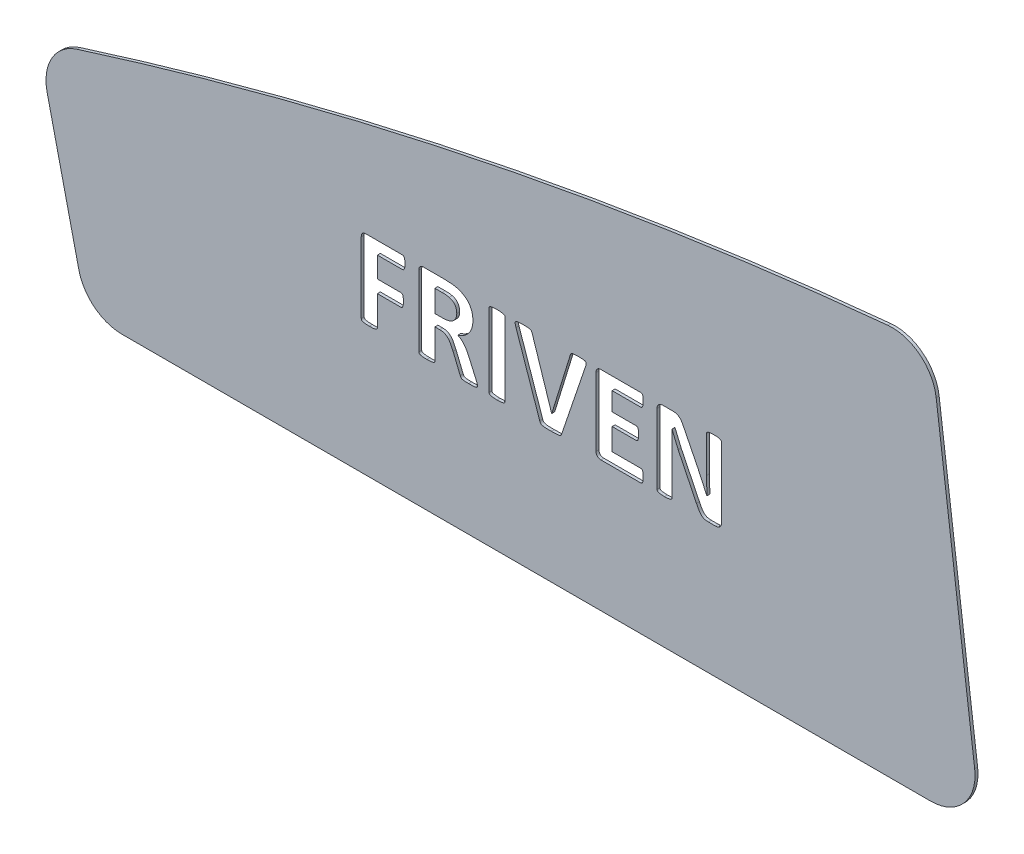
from build123d import *

# Parameters (mm, degrees)
RESSALTO_EXTRUS_O1_DEPTH = 1
CORTE_EXTRUS_O1_DEPTH    = 2.0000001


with BuildPart() as part:
    # Esboço1 → Ressalto-extrusão1 (new body)
    with BuildSketch(Plane.XY):
        with BuildLine():
            Line((94.444598391, 61.667599804), (367.776904696, 61.667599804))
            ThreePointArc((367.776904696, 61.667599804), (379.03385921, 66.75392364), (382.656611581, 78.563469793))
            Line((382.656611581, 78.563469793), (369.641986092, 180.708560753))
            ThreePointArc((369.641986092, 180.708560753), (364.126605538, 190.530599808), (353.330083137, 193.744161368))
            add(Edge.make_bspline(
                [(79.194488068, 137.503422788), (169.384224686, 166.11838017), (260.762756376, 184.86529303), (353.330083137, 193.744161368)],
                knots=[0.031642667, 0.031642667, 0.031642667, 0.031642667, 0.681355193, 0.681355193, 0.681355193, 0.681355193], degree=3))
            ThreePointArc((79.194488068, 137.503422788), (70.703408387, 130.641376571), (69.113130899, 119.840583547))
            Line((69.113130899, 119.840583547), (79.826960066, 73.302388103))
            ThreePointArc((79.826960066, 73.302388103), (85.103243444, 64.931370096), (94.444598391, 61.667599804))
        make_face()
    extrude(amount=RESSALTO_EXTRUS_O1_DEPTH)

    # Esboço2 → Corte-extrusão1 (cut, through all)
    with BuildSketch(Plane.XY.offset(1)):
        with BuildLine():
            add(Edge.make_bspline(
                [(190.074469714, 130.135297285), (190.073615824, 129.952721273), (190.072047442, 129.617375054), (190.025612284, 129.161274081), (189.974615654, 128.78716653), (189.877432942, 128.498499337), (189.758996776, 128.278558112), (189.621720542, 128.122269327), (189.458159733, 128.025974502), (189.34199356, 128.013605785), (189.284124279, 128.007444191)],
                knots=[0, 0, 0, 0, 0.000547297, 0.001005248, 0.001375054, 0.001676898, 0.001913689, 0.002120216, 0.002294415, 0.002467336, 0.002467336, 0.002467336, 0.002467336], degree=3))
            Line((189.284124279, 128.007444191), (180.73623442, 128.007444191))
            Line((180.73623442, 128.007444191), (180.73623442, 121.00376772))
            Line((180.73623442, 121.00376772), (188.755200795, 121.00376772))
            add(Edge.make_bspline(
                [(188.755200795, 121.00376772), (188.813073192, 120.999832249), (188.928600555, 120.991976091), (189.088132877, 120.901725823), (189.236126152, 120.762871005), (189.3470074, 120.541728002), (189.446240967, 120.254949404), (189.496495394, 119.880152168), (189.543567249, 119.420261457), (189.544844107, 119.08081137), (189.545546231, 118.894153367)],
                knots=[0, 0, 0, 0, 0.000171956, 0.000343267, 0.000536766, 0.000773557, 0.001075401, 0.001445208, 0.001903158, 0.002462611, 0.002462611, 0.002462611, 0.002462611], degree=3))
            add(Edge.make_bspline(
                [(189.545546231, 118.894153367), (189.544856054, 118.707506484), (189.543600923, 118.368076621), (189.496192966, 117.906073981), (189.445448264, 117.525808413), (189.345610124, 117.226831185), (189.235032479, 116.99263671), (189.094249199, 116.831280767), (188.927549701, 116.743578819), (188.81282935, 116.730375672), (188.755200795, 116.72374321)],
                knots=[0, 0, 0, 0, 0.000559454, 0.001017404, 0.001393208, 0.001706587, 0.001959457, 0.002165983, 0.002337294, 0.002510215, 0.002510215, 0.002510215, 0.002510215], degree=3))
            Line((188.755200795, 116.72374321), (180.73623442, 116.72374321))
            Line((180.73623442, 116.72374321), (180.73623442, 106.741072408))
            add(Edge.make_bspline(
                [(180.73623442, 106.741072408), (180.731322982, 106.668872202), (180.721688386, 106.527239571), (180.613941345, 106.331580126), (180.424704144, 106.168582967), (180.142156824, 106.050961066), (179.771202878, 105.94719517), (179.293371773, 105.879013596), (178.696208815, 105.840019747), (178.255850081, 105.833008561), (178.012582459, 105.829135367)],
                knots=[0, 0, 0, 0, 0.000214946, 0.000421651, 0.000649858, 0.000951763, 0.001330897, 0.001804676, 0.002395928, 0.003125706, 0.003125706, 0.003125706, 0.003125706], degree=3))
            add(Edge.make_bspline(
                [(178.012582459, 105.829135367), (177.773437513, 105.833330882), (177.335238963, 105.841018557), (176.739358176, 105.877291174), (176.261949751, 105.9507416), (175.888228402, 106.040552911), (175.614218447, 106.167799259), (175.415134127, 106.316961632), (175.312426266, 106.514334314), (175.296802348, 106.652979573), (175.288930498, 106.722833667)],
                knots=[0, 0, 0, 0, 0.000717622, 0.001314939, 0.001788717, 0.002166239, 0.002462646, 0.0026915, 0.002898206, 0.003108106, 0.003108106, 0.003108106, 0.003108106], degree=3))
            Line((175.288930498, 106.722833667), (175.288930498, 130.597345386))
            add(Edge.make_bspline(
                [(175.288930498, 130.597345386), (175.294676682, 130.73559093), (175.305533166, 130.996783546), (175.386853165, 131.357417735), (175.529677887, 131.659860324), (175.735929227, 131.893800085), (175.983966366, 132.070679309), (176.25792759, 132.199189033), (176.559615, 132.274916467), (176.767854396, 132.283185957), (176.875700949, 132.287468701)],
                knots=[0, 0, 0, 0, 0.000414528, 0.000783183, 0.001101302, 0.001407281, 0.001707652, 0.002009557, 0.002310358, 0.002633492, 0.002633492, 0.002633492, 0.002633492], degree=3))
            Line((176.875700949, 132.287468701), (189.278044699, 132.287468701))
            add(Edge.make_bspline(
                [(189.278044699, 132.287468701), (189.338076259, 132.284115623), (189.45686498, 132.277480649), (189.619256436, 132.179904821), (189.756085183, 132.025159638), (189.870977578, 131.801843793), (189.967851713, 131.505262599), (190.027462089, 131.124108941), (190.071310928, 130.659174697), (190.073356877, 130.319858813), (190.074469714, 130.135297285)],
                knots=[0, 0, 0, 0, 0.000177977, 0.000352176, 0.000550113, 0.00079223, 0.001099835, 0.001482655, 0.001946659, 0.002500034, 0.002500034, 0.002500034, 0.002500034], degree=3))
        make_face()
        with BuildLine():
            add(Edge.make_bspline(
                [(214.587337361, 106.637719543), (214.585061708, 106.570340863), (214.580720061, 106.441791176), (214.511741666, 106.25678623), (214.353672168, 106.095934848), (214.078508234, 105.991700878), (213.685426101, 105.912009402), (213.271036266, 105.868007519), (212.859006397, 105.84301419), (212.479628727, 105.844273608), (212.046205483, 105.824576415), (211.740093447, 105.827556702), (211.577945128, 105.829135367)],
                knots=[0, 0, 0, 0, 0.000201453, 0.000384347, 0.000577846, 0.0008581, 0.001250457, 0.001782863, 0.002105597, 0.002488659, 0.00292048, 0.003406846, 0.003406846, 0.003406846, 0.003406846], degree=3))
            add(Edge.make_bspline(
                [(211.577945128, 105.829135367), (211.318615134, 105.832972079), (210.856546314, 105.839808252), (210.240370404, 105.851656107), (209.764366015, 105.914877183), (209.400533767, 105.997080976), (209.130172746, 106.122585477), (208.947673713, 106.294524299), (208.842489111, 106.50376543), (208.782391836, 106.647572918), (208.750940302, 106.722833667)],
                knots=[0, 0, 0, 0, 0.000778281, 0.001386725, 0.001846729, 0.002216835, 0.002502317, 0.0027302, 0.002953412, 0.003198488, 0.003198488, 0.003198488, 0.003198488], degree=3))
            Line((208.750940302, 106.722833667), (206.343426515, 112.607867368))
            add(Edge.make_bspline(
                [(206.343426515, 112.607867368), (206.202043401, 112.925188899), (205.934863175, 113.524850596), (205.516212453, 114.360797994), (205.087748544, 115.084883724), (204.593222382, 115.676197168), (204.037605014, 116.149430953), (203.394006811, 116.482588837), (202.659952119, 116.69239169), (202.137900875, 116.712923034), (201.862775857, 116.72374321)],
                knots=[0, 0, 0, 0, 0.001042023, 0.001969174, 0.002804381, 0.003559449, 0.004271695, 0.004978732, 0.005717795, 0.006541258, 0.006541258, 0.006541258, 0.006541258], degree=3))
            Line((201.862775857, 116.72374321), (200.190891283, 116.72374321))
            Line((200.190891283, 116.72374321), (200.190891283, 106.686356185))
            add(Edge.make_bspline(
                [(200.190891283, 106.686356185), (200.185797325, 106.620112443), (200.175416399, 106.485114959), (200.060535528, 106.300416451), (199.869363014, 106.147465128), (199.588168031, 106.03777516), (199.217674696, 105.951458951), (198.742345554, 105.877378866), (198.142624739, 105.840453206), (197.700326055, 105.83317242), (197.455080161, 105.829135367)],
                knots=[0, 0, 0, 0, 0.000196907, 0.000401275, 0.000630129, 0.000921505, 0.001297507, 0.001771285, 0.002362538, 0.003098393, 0.003098393, 0.003098393, 0.003098393], degree=3))
            add(Edge.make_bspline(
                [(197.455080161, 105.829135367), (197.215931371, 105.833333815), (196.777725779, 105.841026865), (196.179886764, 105.877388326), (195.70090928, 105.951405309), (195.328790855, 106.035843776), (195.05313787, 106.149938501), (194.859268071, 106.296822059), (194.761709654, 106.488695685), (194.749611918, 106.62064612), (194.743587361, 106.686356185)],
                knots=[0, 0, 0, 0, 0.000717622, 0.001314939, 0.001794725, 0.002170727, 0.002456532, 0.002685386, 0.002883882, 0.003080789, 0.003080789, 0.003080789, 0.003080789], degree=3))
            Line((194.743587361, 106.686356185), (194.743587361, 130.597345386))
            add(Edge.make_bspline(
                [(194.743587361, 130.597345386), (194.74954361, 130.735485009), (194.76079698, 130.996477502), (194.839706103, 131.359318851), (194.991538603, 131.65829419), (195.196214772, 131.894051464), (195.444844671, 132.070518268), (195.720334745, 132.200427997), (196.024617996, 132.274195393), (196.234723533, 132.282967977), (196.342516972, 132.287468701)],
                knots=[0, 0, 0, 0, 0.000414528, 0.000783183, 0.001104021, 0.00141, 0.00171037, 0.002012275, 0.002318978, 0.002642112, 0.002642112, 0.002642112, 0.002642112], degree=3))
            Line((196.342516972, 132.287468701), (203.200283516, 132.287468701))
            add(Edge.make_bspline(
                [(203.200283516, 132.287468701), (203.366476938, 132.288738303), (203.684730576, 132.29116954), (204.138550757, 132.274709286), (204.546089361, 132.265961955), (205.016230874, 132.239778773), (205.545757915, 132.208036749), (205.954433633, 132.167110774), (206.148879947, 132.147638354)],
                knots=[0, 0, 0, 0, 0.000498526, 0.000954656, 0.00136217, 0.001721328, 0.002367167, 0.002953366, 0.002953366, 0.002953366, 0.002953366], degree=3))
            add(Edge.make_bspline(
                [(206.148879947, 132.147638354), (206.408743461, 132.10573975), (206.919056548, 132.023460381), (207.662503652, 131.856566784), (208.361397787, 131.634481267), (209.02165765, 131.381470524), (209.638022166, 131.082648678), (210.208151312, 130.743936139), (210.732849017, 130.365265653), (211.199621245, 129.937191845), (211.622871307, 129.472758691), (211.997235251, 128.96854387), (212.306302385, 128.414148945), (212.568843542, 127.824610444), (212.776488391, 127.19129397), (212.929909442, 126.516147137), (213.012719539, 125.792490633), (213.024763861, 125.296148147), (213.030964812, 125.040609019)],
                knots=[0, 0, 0, 0, 0.000789597, 0.001550589, 0.002283198, 0.002987695, 0.00367018, 0.004335387, 0.004975016, 0.005607672, 0.00623174, 0.006857967, 0.007486873, 0.008131939, 0.00879137, 0.009483108, 0.01020553, 0.01097216, 0.01097216, 0.01097216, 0.01097216], degree=3))
            add(Edge.make_bspline(
                [(213.030964812, 125.040609019), (213.028988511, 124.823517426), (213.025136437, 124.400376827), (212.950386583, 123.779776597), (212.855277525, 123.186089256), (212.698361077, 122.624678052), (212.510942691, 122.093774887), (212.285102993, 121.590318655), (212.016898087, 121.117351766), (211.713036865, 120.669187241), (211.362330694, 120.256055439), (210.980120404, 119.865862566), (210.558139099, 119.503994775), (209.933057632, 119.06561458), (209.06633485, 118.572327062), (208.30806726, 118.303090642), (207.918037805, 118.164603734)],
                knots=[0, 0, 0, 0, 0.000650771, 0.001268439, 0.001873136, 0.00245274, 0.003014238, 0.003561164, 0.004105617, 0.004643549, 0.005182989, 0.005728968, 0.006280906, 0.00684771, 0.008018089, 0.009257727, 0.009257727, 0.009257727, 0.009257727], degree=3))
            add(Edge.make_bspline(
                [(207.918037805, 118.164603734), (208.117106709, 118.063540911), (208.515343097, 117.861365217), (209.071026448, 117.478105784), (209.599063893, 117.029606374), (210.083414075, 116.486573407), (210.54527994, 115.866072525), (210.977983353, 115.157840455), (211.391919766, 114.361652035), (211.645851475, 113.792801291), (211.778571276, 113.495486087)],
                knots=[0, 0, 0, 0, 0.000669113, 0.001338557, 0.002019742, 0.002742777, 0.003516104, 0.00433777, 0.005229709, 0.006206328, 0.006206328, 0.006206328, 0.006206328], degree=3))
            Line((211.778571276, 113.495486087), (214.064493458, 108.321763278))
            add(Edge.make_bspline(
                [(214.064493458, 108.321763278), (214.11380818, 108.202463812), (214.204535552, 107.982981141), (214.320286704, 107.67624282), (214.412675098, 107.42114832), (214.496026464, 107.163099595), (214.568268584, 106.909181197), (214.581616772, 106.719157409), (214.587337361, 106.637719543)],
                knots=[0, 0, 0, 0, 0.000387236, 0.000712423, 0.000983561, 0.001200816, 0.001526684, 0.00177108, 0.00177108, 0.00177108, 0.00177108], degree=3))
        make_face()
        with BuildLine():
            add(Edge.make_bspline(
                [(207.58366089, 124.359696029), (207.577679133, 124.566991555), (207.566082997, 124.968851208), (207.447731596, 125.544582913), (207.258133173, 126.069533393), (206.995560447, 126.546682349), (206.644205783, 126.967938166), (206.193379941, 127.321199225), (205.64508711, 127.600884923), (205.2373157, 127.724145937), (205.024157597, 127.788579301)],
                knots=[0, 0, 0, 0, 0.000621189, 0.001204227, 0.001754286, 0.002290462, 0.002829903, 0.003388199, 0.003997281, 0.004664402, 0.004664402, 0.004664402, 0.004664402], degree=3))
            add(Edge.make_bspline(
                [(205.024157597, 127.788579301), (204.876608143, 127.821026812), (204.565255862, 127.889496102), (204.153793457, 127.942911094), (203.777957699, 127.971908261), (203.439941813, 128.001536702), (203.050250363, 127.999972334), (202.774687457, 128.004857799), (202.628802971, 128.007444191)],
                knots=[0, 0, 0, 0, 0.000453082, 0.000956073, 0.001242846, 0.00158417, 0.001973311, 0.002411083, 0.002411083, 0.002411083, 0.002411083], degree=3))
            Line((202.628802971, 128.007444191), (200.190891283, 128.007444191))
            Line((200.190891283, 128.007444191), (200.190891283, 120.614674583))
            Line((200.190891283, 120.614674583), (202.957100305, 120.614674583))
            add(Edge.make_bspline(
                [(202.957100305, 120.614674583), (203.143631916, 120.618531796), (203.505189803, 120.626008309), (204.031822371, 120.673518616), (204.521388831, 120.75842622), (204.97809763, 120.872744116), (205.394151628, 121.024798379), (205.777473811, 121.202343945), (206.122695898, 121.407019593), (206.529987889, 121.715290658), (206.952957024, 122.174225247), (207.321624628, 122.827065783), (207.545010252, 123.567249678), (207.570537719, 124.090634262), (207.58366089, 124.359696029)],
                knots=[0, 0, 0, 0, 0.000559619, 0.00108472, 0.001584467, 0.002048949, 0.002495125, 0.002911255, 0.003314758, 0.003696563, 0.004440883, 0.005167819, 0.005929491, 0.006735305, 0.006735305, 0.006735305, 0.006735305], degree=3))
        make_face(mode=Mode.SUBTRACT)
        with BuildLine():
            add(Edge.make_bspline(
                [(223.925572655, 106.680276605), (223.920162719, 106.616159709), (223.908961259, 106.483403447), (223.795366727, 106.300073716), (223.602694414, 106.148615741), (223.327330889, 106.029106049), (222.955106947, 105.954031012), (222.483444903, 105.876274958), (221.885291656, 105.840971493), (221.445097434, 105.833347239), (221.201920694, 105.829135367)],
                knots=[0, 0, 0, 0, 0.000190903, 0.000395271, 0.000624125, 0.000917964, 0.001286619, 0.001760398, 0.002351651, 0.003081428, 0.003081428, 0.003081428, 0.003081428], degree=3))
            add(Edge.make_bspline(
                [(221.201920694, 105.829135367), (220.962816591, 105.833535308), (220.524692882, 105.841597564), (219.928354272, 105.875578726), (219.453169701, 105.955146482), (219.07791921, 106.027851522), (218.8020868, 106.149126215), (218.606757026, 106.298195955), (218.503710169, 106.485809782), (218.486613054, 106.616495081), (218.478268734, 106.680276605)],
                knots=[0, 0, 0, 0, 0.000717622, 0.001314939, 0.001788717, 0.002163291, 0.00245713, 0.002685984, 0.002887346, 0.00307931, 0.00307931, 0.00307931, 0.00307931], degree=3))
            Line((218.478268734, 106.680276605), (218.478268734, 131.436327463))
            add(Edge.make_bspline(
                [(218.478268734, 131.436327463), (218.486022383, 131.50235081), (218.501456185, 131.633771677), (218.609449462, 131.820864812), (218.806247677, 131.966671854), (219.088129311, 132.080517953), (219.462122729, 132.164219134), (219.937106893, 132.237286722), (220.528170183, 132.285919531), (220.962684964, 132.286918621), (221.201920694, 132.287468701)],
                knots=[0, 0, 0, 0, 0.000197937, 0.000393997, 0.000627567, 0.000918943, 0.001300846, 0.001774624, 0.002360287, 0.00307778, 0.00307778, 0.00307778, 0.00307778], degree=3))
            add(Edge.make_bspline(
                [(221.201920694, 132.287468701), (221.445236486, 132.287007508), (221.885872915, 132.286172304), (222.482727487, 132.23702709), (222.956755659, 132.166596566), (223.32448283, 132.077642264), (223.604396626, 131.96940247), (223.792922287, 131.816754788), (223.911313725, 131.636410915), (223.920837632, 131.502770024), (223.925572655, 131.436327463)],
                knots=[0, 0, 0, 0, 0.000729651, 0.001321372, 0.001795151, 0.002165257, 0.002456633, 0.002685487, 0.002884634, 0.003081541, 0.003081541, 0.003081541, 0.003081541], degree=3))
            Line((223.925572655, 131.436327463), (223.925572655, 106.680276605))
        make_face()
        with BuildLine():
            add(Edge.make_bspline(
                [(243.076250504, 106.880902754), (243.041917466, 106.775846878), (242.97782773, 106.579738301), (242.820574512, 106.319374555), (242.586859705, 106.110860081), (242.245451332, 105.978370283), (241.793597084, 105.892306838), (241.338039766, 105.86019851), (240.899790902, 105.847128346), (240.508729594, 105.833252448), (240.066872939, 105.827905816), (239.756799883, 105.828709766), (239.59265101, 105.829135367)],
                knots=[0, 0, 0, 0, 0.000330877, 0.00061765, 0.000901899, 0.001253149, 0.001700277, 0.002279882, 0.002620555, 0.003015915, 0.003453687, 0.003946133, 0.003946133, 0.003946133, 0.003946133], degree=3))
            add(Edge.make_bspline(
                [(239.59265101, 105.829135367), (239.337311468, 105.828768784), (238.865126496, 105.828090883), (238.210414596, 105.832365258), (237.658833217, 105.848270948), (237.19963441, 105.881501317), (236.824733564, 105.938048409), (236.51827191, 105.998691386), (236.274582937, 106.094113295), (236.073660014, 106.201346139), (235.91676278, 106.339361383), (235.793689931, 106.50712413), (235.707839622, 106.713806389), (235.656270845, 106.86242641), (235.628764674, 106.941698557)],
                knots=[0, 0, 0, 0, 0.000766027, 0.001416571, 0.001964037, 0.002421462, 0.002796331, 0.003101645, 0.003355681, 0.003578894, 0.003781354, 0.003977131, 0.004197511, 0.004449428, 0.004449428, 0.004449428, 0.004449428], degree=3))
            Line((235.628764674, 106.941698557), (227.621957459, 130.177854347))
            add(Edge.make_bspline(
                [(227.621957459, 130.177854347), (227.585392662, 130.293316768), (227.516309199, 130.511464951), (227.420932686, 130.817515734), (227.363304996, 131.089160009), (227.313958769, 131.320497909), (227.302366428, 131.525601268), (227.342183508, 131.700909156), (227.407740054, 131.855643015), (227.524383594, 131.980947956), (227.683378325, 132.080500195), (227.887926067, 132.148673319), (228.132440682, 132.202928517), (228.423736955, 132.237167792), (228.76669442, 132.259048622), (229.170002488, 132.279366129), (229.634322239, 132.280645927), (229.96463148, 132.285112253), (230.138903691, 132.287468701)],
                knots=[0, 0, 0, 0, 0.000363404, 0.000686596, 0.000960919, 0.00119583, 0.001396548, 0.001570641, 0.001731146, 0.001894731, 0.002075183, 0.002288662, 0.002537925, 0.002825984, 0.003167308, 0.003568975, 0.004037142, 0.004560021, 0.004560021, 0.004560021, 0.004560021], degree=3))
            add(Edge.make_bspline(
                [(230.138903691, 132.287468701), (230.288889882, 132.288808028), (230.570683049, 132.291324349), (230.967730589, 132.274871683), (231.312526697, 132.266038809), (231.685808784, 132.241988344), (232.062735264, 132.205706922), (232.42651556, 132.123666169), (232.698897489, 132.003593547), (232.862122936, 131.799466504), (232.976915786, 131.564379877), (233.036838212, 131.390552582), (233.069261381, 131.296497117)],
                knots=[0, 0, 0, 0, 0.000449889, 0.000845249, 0.001191998, 0.001484387, 0.001967781, 0.002324616, 0.002604673, 0.002837451, 0.00309032, 0.003388468, 0.003388468, 0.003388468, 0.003388468], degree=3))
            Line((233.069261381, 131.296497117), (239.665605973, 111.07581314))
            Line((239.665605973, 111.07581314), (239.683844714, 111.07581314))
            Line((239.683844714, 111.07581314), (245.90933491, 131.193144252))
            add(Edge.make_bspline(
                [(245.90933491, 131.193144252), (245.939894091, 131.298884937), (245.995090873, 131.489876488), (246.099767379, 131.757017168), (246.287681739, 131.961719052), (246.565062571, 132.111280568), (246.947172617, 132.208552755), (247.343410649, 132.24204834), (247.730951397, 132.265874701), (248.091917799, 132.27497489), (248.503168971, 132.291227266), (248.795088081, 132.288766941), (248.949125045, 132.287468701)],
                knots=[0, 0, 0, 0, 0.000330765, 0.000597436, 0.0008514, 0.001145491, 0.001530477, 0.002025954, 0.002336548, 0.00269545, 0.00310904, 0.003571088, 0.003571088, 0.003571088, 0.003571088], degree=3))
            add(Edge.make_bspline(
                [(248.949125045, 132.287468701), (249.099056943, 132.28480256), (249.382715025, 132.279758454), (249.780581357, 132.282313937), (250.124487942, 132.25047386), (250.419719283, 132.232895668), (250.668826238, 132.19182192), (250.876348237, 132.131540544), (251.04465131, 132.050574817), (251.203944416, 131.898947752), (251.32335118, 131.629660342), (251.28724618, 131.22642178), (251.168524523, 130.724133619), (251.040580724, 130.353148707), (250.967545694, 130.141376865)],
                knots=[0, 0, 0, 0, 0.00044993, 0.000851228, 0.001192552, 0.001485384, 0.001738253, 0.001947889, 0.002132792, 0.00229191, 0.002599335, 0.002976318, 0.003480776, 0.004151765, 0.004151765, 0.004151765, 0.004151765], degree=3))
            Line((250.967545694, 130.141376865), (243.076250504, 106.880902754))
        make_face()
        with BuildLine():
            add(Edge.make_bspline(
                [(270.616749126, 107.969147622), (270.615875469, 107.784563014), (270.614278812, 107.447223949), (270.568591974, 106.988867238), (270.515072078, 106.616053164), (270.424820072, 106.324449535), (270.309253712, 106.099439162), (270.162593852, 105.941285394), (269.989297836, 105.848762684), (269.86787574, 105.835605549), (269.80816495, 105.829135367)],
                knots=[0, 0, 0, 0, 0.000553375, 0.001011326, 0.001381132, 0.001681072, 0.001923189, 0.002133879, 0.002318782, 0.002497692, 0.002497692, 0.002497692, 0.002497692], degree=3))
            Line((269.80816495, 105.829135367), (256.28717843, 105.829135367))
            add(Edge.make_bspline(
                [(256.28717843, 105.829135367), (256.177427342, 105.833764072), (255.963454693, 105.842788276), (255.6541725, 105.914362989), (255.378276807, 106.048594087), (255.121704215, 106.215591341), (254.907858574, 106.452713546), (254.76453939, 106.759305701), (254.679162703, 107.123560077), (254.669251868, 107.384977079), (254.663930498, 107.525338262)],
                knots=[0, 0, 0, 0, 0.000329197, 0.000641808, 0.000943713, 0.001245556, 0.001555555, 0.001887269, 0.002250011, 0.002670602, 0.002670602, 0.002670602, 0.002670602], degree=3))
            Line((254.663930498, 107.525338262), (254.663930498, 130.591265805))
            add(Edge.make_bspline(
                [(254.663930498, 130.591265805), (254.669360415, 130.731585796), (254.679473415, 130.992926079), (254.763119213, 131.355898988), (254.9094325, 131.659368071), (255.123524924, 131.894083114), (255.377455358, 132.07072336), (255.659151541, 132.200450013), (255.971328569, 132.27466352), (256.187482401, 132.283101973), (256.299337591, 132.287468701)],
                knots=[0, 0, 0, 0, 0.000420591, 0.000783334, 0.001109598, 0.001419597, 0.001724911, 0.002032336, 0.002344947, 0.002680207, 0.002680207, 0.002680207, 0.002680207], degree=3))
            Line((256.299337591, 132.287468701), (269.82032411, 132.287468701))
            add(Edge.make_bspline(
                [(269.82032411, 132.287468701), (269.879995982, 132.283330278), (269.998920481, 132.275082509), (270.16609858, 132.189265745), (270.309710465, 132.034294584), (270.416209726, 131.802084236), (270.516864127, 131.503831722), (270.567323781, 131.123309852), (270.61501768, 130.659379347), (270.616132902, 130.317902819), (270.616749126, 130.129217705)],
                knots=[0, 0, 0, 0, 0.000177977, 0.000354704, 0.000548202, 0.000801072, 0.001114451, 0.001490255, 0.001948206, 0.002513737, 0.002513737, 0.002513737, 0.002513737], degree=3))
            add(Edge.make_bspline(
                [(270.616749126, 130.129217705), (270.615947837, 129.948659948), (270.614477504, 129.617343396), (270.567381577, 129.165383843), (270.517200662, 128.793185619), (270.418370737, 128.503046081), (270.302224813, 128.28230566), (270.169128742, 128.118411894), (269.99966112, 128.026347975), (269.880034283, 128.013738197), (269.82032411, 128.007444191)],
                knots=[0, 0, 0, 0, 0.000541219, 0.000993117, 0.001362923, 0.001664767, 0.001906884, 0.002109344, 0.002288871, 0.002467781, 0.002467781, 0.002467781, 0.002467781], degree=3))
            Line((269.82032411, 128.007444191), (260.11123442, 128.007444191))
            Line((260.11123442, 128.007444191), (260.11123442, 121.781953995))
            Line((260.11123442, 121.781953995), (268.245712821, 121.781953995))
            add(Edge.make_bspline(
                [(268.245712821, 121.781953995), (268.307848067, 121.776308037), (268.433085056, 121.764928301), (268.602300766, 121.662291142), (268.755342648, 121.512389123), (268.867732084, 121.285896994), (268.960528069, 120.991535695), (269.010741334, 120.613784526), (269.058267721, 120.151793354), (269.059630754, 119.814397992), (269.060376577, 119.629782579)],
                knots=[0, 0, 0, 0, 0.000184903, 0.000372683, 0.00057903, 0.000821147, 0.001121087, 0.001502892, 0.001960843, 0.002514218, 0.002514218, 0.002514218, 0.002514218], degree=3))
            add(Edge.make_bspline(
                [(269.060376577, 119.629782579), (269.059444386, 119.443184396), (269.057739048, 119.101823993), (269.012762415, 118.639275334), (268.95833133, 118.26468398), (268.8699129, 117.974212932), (268.752736777, 117.753490219), (268.605809082, 117.601079964), (268.430103167, 117.514258264), (268.307379236, 117.506052649), (268.245712821, 117.501929485)],
                knots=[0, 0, 0, 0, 0.000559454, 0.001023457, 0.001393264, 0.001693203, 0.001929995, 0.002136343, 0.002318528, 0.002502529, 0.002502529, 0.002502529, 0.002502529], degree=3))
            Line((268.245712821, 117.501929485), (260.11123442, 117.501929485))
            Line((260.11123442, 117.501929485), (260.11123442, 110.109159877))
            Line((260.11123442, 110.109159877), (269.80816495, 110.109159877))
            add(Edge.make_bspline(
                [(269.80816495, 110.109159877), (269.867951188, 110.102757835), (269.989526709, 110.08973926), (270.160286357, 109.996808369), (270.313262923, 109.844051639), (270.422442003, 109.614374174), (270.516559833, 109.320792357), (270.567240883, 108.94709113), (270.614839809, 108.489158862), (270.616071251, 108.153770072), (270.616749126, 107.969147622)],
                knots=[0, 0, 0, 0, 0.000178909, 0.000363812, 0.00057016, 0.000817637, 0.001117577, 0.001493381, 0.001945279, 0.002498654, 0.002498654, 0.002498654, 0.002498654], degree=3))
        make_face()
        with BuildLine():
            add(Edge.make_bspline(
                [(297.075082459, 107.744203152), (297.067862795, 107.595143348), (297.053918337, 107.307241016), (296.920725739, 106.908221223), (296.724938478, 106.565420419), (296.46322497, 106.286696073), (296.146972056, 106.068474994), (295.781806368, 105.926992809), (295.392202579, 105.850250905), (295.127900598, 105.836169746), (294.995866007, 105.829135367)],
                knots=[0, 0, 0, 0, 0.000445845, 0.00086113, 0.001247984, 0.001622212, 0.001998262, 0.002391137, 0.002788176, 0.003184516, 0.003184516, 0.003184516, 0.003184516], degree=3))
            Line((294.995866007, 105.829135367), (292.636988862, 105.829135367))
            add(Edge.make_bspline(
                [(292.636988862, 105.829135367), (292.407644134, 105.835475345), (291.980341359, 105.847287651), (291.371924648, 105.951273002), (290.834101897, 106.172207869), (290.347000873, 106.513957493), (289.89749859, 106.985987004), (289.470675832, 107.599757866), (289.03982339, 108.368771182), (288.759213225, 108.940330289), (288.606227144, 109.251939059)],
                knots=[0, 0, 0, 0, 0.00068796, 0.001281771, 0.001840629, 0.002417389, 0.003053686, 0.003785865, 0.004654565, 0.005695896, 0.005695896, 0.005695896, 0.005695896], degree=3))
            Line((288.606227144, 109.251939059), (282.43545317, 121.873147699))
            add(Edge.make_bspline(
                [(282.43545317, 121.873147699), (282.253696337, 122.261597551), (281.877733634, 123.065103281), (281.332563703, 124.301120029), (280.818700985, 125.569469472), (280.500274617, 126.421982997), (280.344077557, 126.840164779)],
                knots=[0, 0, 0, 0, 0.001286589, 0.0026613, 0.004052183, 0.005391348, 0.005391348, 0.005391348, 0.005391348], degree=3))
            Line((280.344077557, 126.840164779), (280.301520495, 126.840164779))
            add(Edge.make_bspline(
                [(280.301520495, 126.840164779), (280.312990178, 126.34166118), (280.335880941, 125.346766401), (280.34628686, 123.849023572), (280.343501511, 122.331143856), (280.343883521, 121.309773634), (280.344077557, 120.790982411)],
                knots=[0, 0, 0, 0, 0.001495886, 0.002985432, 0.004493168, 0.006049541, 0.006049541, 0.006049541, 0.006049541], degree=3))
            Line((280.344077557, 120.790982411), (280.344077557, 106.722833667))
            add(Edge.make_bspline(
                [(280.344077557, 106.722833667), (280.337940083, 106.657063157), (280.325446693, 106.523181261), (280.229284379, 106.33377867), (280.055847815, 106.173372221), (279.80162249, 106.047358166), (279.454467391, 105.956489247), (279.007858518, 105.875416663), (278.437560213, 105.841122857), (278.017613788, 105.833413497), (277.784574264, 105.829135367)],
                knots=[0, 0, 0, 0, 0.000196907, 0.000400822, 0.000620109, 0.000894769, 0.001243007, 0.001693799, 0.002254737, 0.002954127, 0.002954127, 0.002954127, 0.002954127], degree=3))
            add(Edge.make_bspline(
                [(277.784574264, 105.829135367), (277.557599664, 105.83330519), (277.143709783, 105.840908894), (276.581996798, 105.877086422), (276.137184142, 105.950747368), (275.793551573, 106.037702228), (275.551146246, 106.169921345), (275.380585748, 106.319776118), (275.298863971, 106.509218835), (275.290220255, 106.639152634), (275.285866773, 106.704594926)],
                knots=[0, 0, 0, 0, 0.000681157, 0.001242095, 0.001685863, 0.002034101, 0.002298056, 0.002508747, 0.002701959, 0.002898019, 0.002898019, 0.002898019, 0.002898019], degree=3))
            Line((275.285866773, 106.704594926), (275.285866773, 130.372400916))
            add(Edge.make_bspline(
                [(275.285866773, 130.372400916), (275.291933063, 130.523148688), (275.303431604, 130.808888275), (275.414477747, 131.207885491), (275.598912778, 131.548728262), (275.863747135, 131.817500118), (276.17294677, 132.03240224), (276.527145281, 132.175315891), (276.908040358, 132.271889866), (277.173958744, 132.28218672), (277.310367003, 132.287468701)],
                knots=[0, 0, 0, 0, 0.000451365, 0.000855555, 0.001231113, 0.00160092, 0.00197697, 0.002352971, 0.00274078, 0.003149245, 0.003149245, 0.003149245, 0.003149245], degree=3))
            Line((277.310367003, 132.287468701), (280.313679656, 132.287468701))
            add(Edge.make_bspline(
                [(280.313679656, 132.287468701), (280.563503485, 132.284348796), (281.021181112, 132.278633127), (281.654491201, 132.171699264), (282.203327013, 132.00431721), (282.682289168, 131.725478327), (283.119569871, 131.349147396), (283.515416534, 130.854465816), (283.893011112, 130.243550444), (284.115752522, 129.785005001), (284.23500893, 129.539498419)],
                knots=[0, 0, 0, 0, 0.000748406, 0.001371081, 0.001920938, 0.002460105, 0.003020615, 0.003642577, 0.004352744, 0.005171142, 0.005171142, 0.005171142, 0.005171142], degree=3))
            Line((284.23500893, 129.539498419), (289.043956923, 119.915522852))
            add(Edge.make_bspline(
                [(289.043956923, 119.915522852), (289.184191362, 119.625922911), (289.46150692, 119.053234988), (289.86803698, 118.19571954), (290.281225106, 117.354277456), (290.664956065, 116.509740315), (291.043335811, 115.677490545), (291.407883225, 114.853698397), (291.768548512, 114.037863888), (292.003106171, 113.493643079), (292.120224539, 113.221904975)],
                knots=[0, 0, 0, 0, 0.000965295, 0.001908884, 0.002846993, 0.003777328, 0.004691552, 0.005589706, 0.00647984, 0.007367542, 0.007367542, 0.007367542, 0.007367542], degree=3))
            Line((292.120224539, 113.221904975), (292.13846328, 113.221904975))
            add(Edge.make_bspline(
                [(292.13846328, 113.221904975), (292.118669033, 113.704169306), (292.078257546, 114.688749202), (292.046603965, 116.176488972), (292.018982456, 117.659897085), (292.017563513, 118.640824205), (292.016871675, 119.119097837)],
                knots=[0, 0, 0, 0, 0.001447974, 0.002956151, 0.004464083, 0.005898877, 0.005898877, 0.005898877, 0.005898877], degree=3))
            Line((292.016871675, 119.119097837), (292.016871675, 131.418088722))
            add(Edge.make_bspline(
                [(292.016871675, 131.418088722), (292.022273956, 131.482230838), (292.033224481, 131.612248084), (292.143327827, 131.793079265), (292.325657524, 131.948689957), (292.589352358, 132.081218016), (292.943311481, 132.181559396), (293.397279807, 132.241204175), (293.965533158, 132.284904101), (294.385757753, 132.286553488), (294.61893203, 132.287468701)],
                knots=[0, 0, 0, 0, 0.000190903, 0.000386963, 0.00061517, 0.000903422, 0.001265042, 0.001713862, 0.0022748, 0.002974057, 0.002974057, 0.002974057, 0.002974057], degree=3))
            add(Edge.make_bspline(
                [(294.61893203, 132.287468701), (294.841984965, 132.286514663), (295.248056674, 132.28477782), (295.79996602, 132.240391173), (296.240491142, 132.18379843), (296.57553393, 132.083420743), (296.813173929, 131.947954148), (296.969083282, 131.788512738), (297.065183424, 131.608035175), (297.071750264, 131.477995058), (297.075082459, 131.412009142)],
                knots=[0, 0, 0, 0, 0.000668864, 0.001217679, 0.001660488, 0.001998875, 0.00226058, 0.002471271, 0.002661592, 0.002857652, 0.002857652, 0.002857652, 0.002857652], degree=3))
            Line((297.075082459, 131.412009142), (297.075082459, 107.744203152))
        make_face()
    extrude(amount=-CORTE_EXTRUS_O1_DEPTH, mode=Mode.SUBTRACT)


solid = part.part
